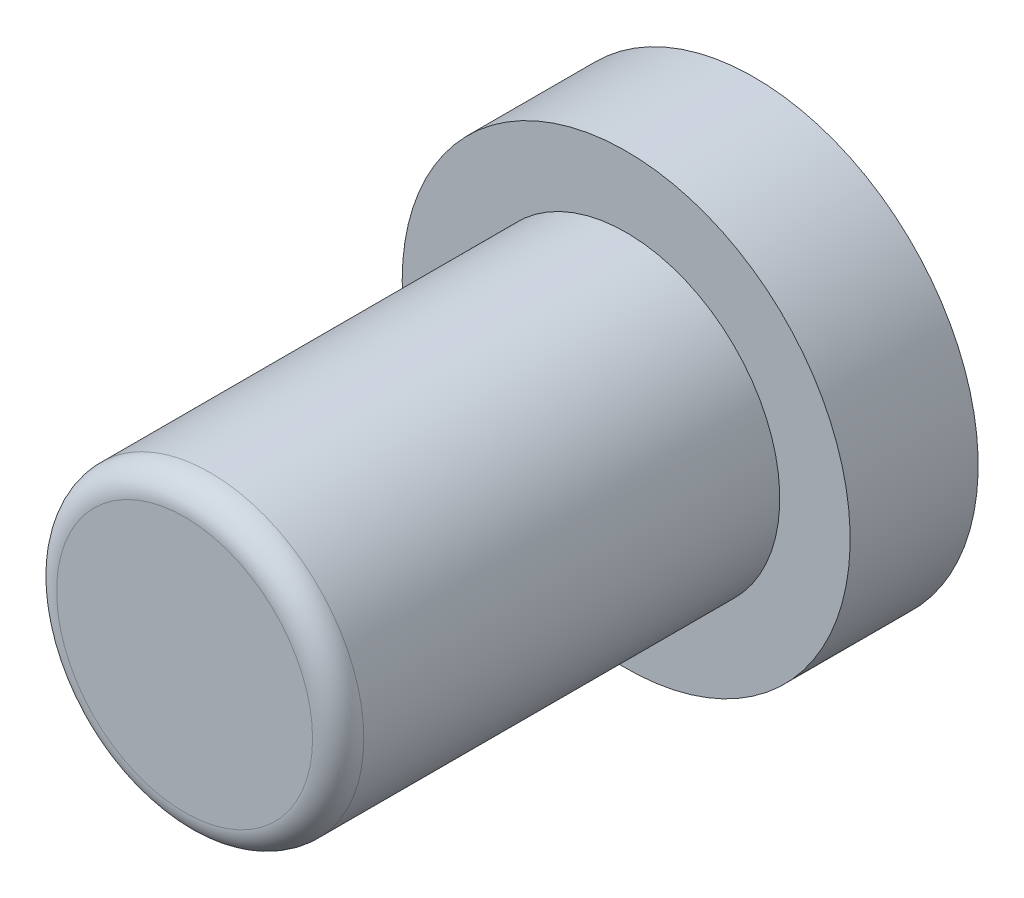
from build123d import *

# Parameters (mm, degrees)
SKETCH1_R           = 4.8
BOSS_EXTRUDE1_DEPTH = 8.9
FILLET1_R           = 0.8
SKETCH2_R           = 7
BOSS_EXTRUDE2_DEPTH = 4


with BuildPart() as part:
    # Sketch1 → Boss-Extrude1 (new body, symmetric)
    with BuildSketch(Plane.XY):
        Circle(SKETCH1_R)
    extrude(amount=BOSS_EXTRUDE1_DEPTH, both=True)

    # Fillet1
    fillet1_edges = [part.edges().sort_by_distance(p)[0] for p in [
        (-4.8, 0, 8.9),
    ]]
    fillet(fillet1_edges, radius=FILLET1_R)

    # Sketch2 → Boss-Extrude2 (add)
    with BuildSketch(Plane(origin=(0, 0, -8.9), x_dir=(-1, 0, 0), z_dir=(0, 0, -1))):
        Circle(SKETCH2_R)
    extrude(amount=-BOSS_EXTRUDE2_DEPTH)


solid = part.part
